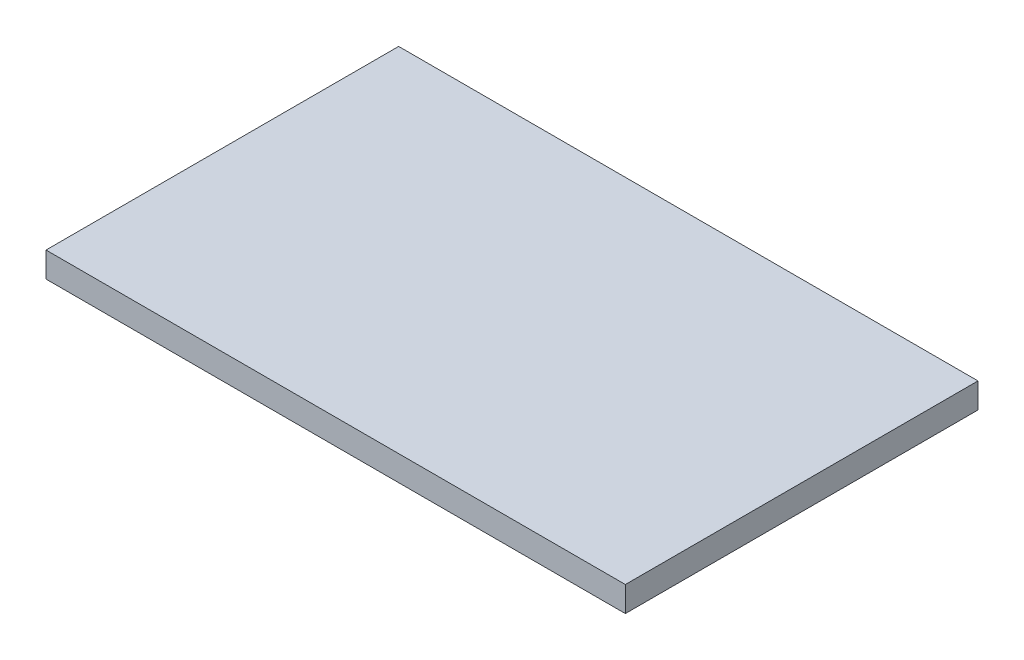
from build123d import *

# Parameters (mm, degrees)
SKETCH1_W           = 1168.4
SKETCH1_H           = 711.2
BOSS_EXTRUDE1_DEPTH = 50.8


with BuildPart() as part:
    # Sketch1 → Boss-Extrude1 (new body)
    with BuildSketch(Plane(origin=(0, 0, 0), x_dir=(1, 0, 0), z_dir=(0, 1, 0))):
        Rectangle(SKETCH1_W, SKETCH1_H)
    extrude(amount=BOSS_EXTRUDE1_DEPTH)


solid = part.part
